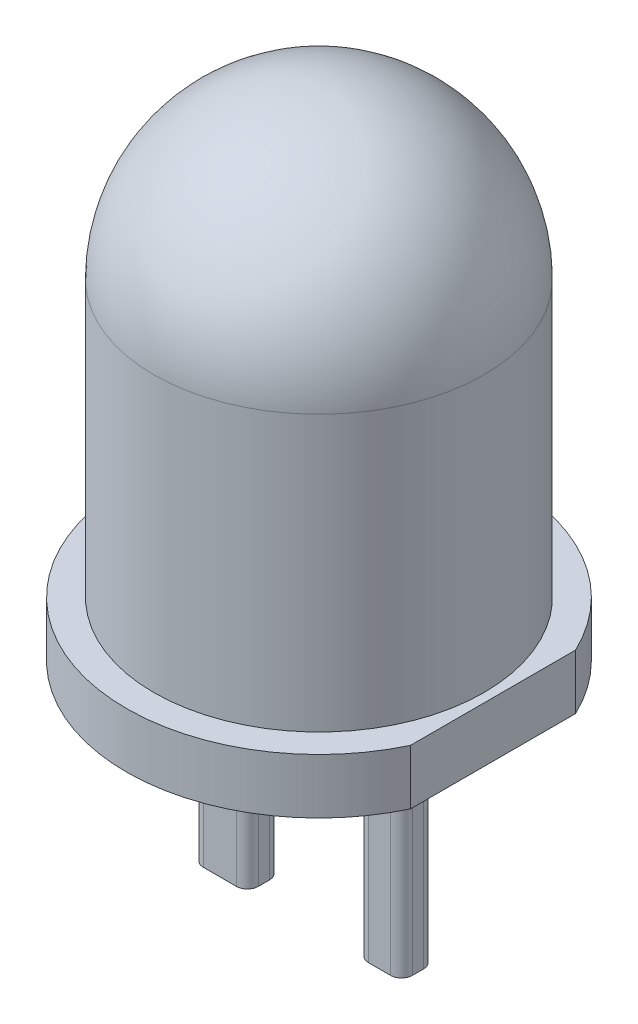
from build123d import *

# Parameters (mm, degrees)
SCHNITT_LINEAR_AUSTRAGEN1_DEPTH = 1
LINEAR_AUSTRAGEN1_DEPTH         = 2


with BuildPart() as part:
    # Skizze2 → Rotation1 (revolve)
    with BuildSketch(Plane.XY):
        with BuildLine():
            Line((0, 0), (-1.75, 0))
            Line((-1.75, 0), (-1.75, 0.5))
            Line((-1.75, 0.5), (-1.5, 0.5))
            Line((-1.5, 0.5), (-1.5, 3))
            ThreePointArc((-1.5, 3), (-1.060660172, 4.060660172), (0, 4.5))
            Line((0, 4.5), (0, 0))
        make_face()
    revolve(axis=Axis((0, 0, 0), (0, 1, 0)))

    # Skizze3 → Schnitt-Linear austragen1 (cut)
    with BuildSketch(Plane.XZ):
        with BuildLine():
            Line((1.58113883, -0.75), (1.58113883, 0.75))
            ThreePointArc((1.58113883, 0.75), (1.75, 0), (1.58113883, -0.75))
        make_face()
    extrude(amount=-SCHNITT_LINEAR_AUSTRAGEN1_DEPTH, mode=Mode.SUBTRACT)

    # Skizze4 → Linear austragen1 (add)
    with BuildSketch(Plane.XZ):
        with BuildLine():
            Line((0.6, 0.15), (0.8, 0.15))
            ThreePointArc((0.8, 0.15), (0.870710678, 0.120710678), (0.9, 0.05))
            Line((0.9, 0.05), (0.9, -0.05))
            ThreePointArc((0.9, -0.05), (0.870710678, -0.120710678), (0.8, -0.15))
            Line((0.8, -0.15), (0.6, -0.15))
            ThreePointArc((0.6, -0.15), (0.529289322, -0.120710678), (0.5, -0.05))
            Line((0.5, -0.05), (0.5, 0.05))
            ThreePointArc((0.5, 0.05), (0.529289322, 0.120710678), (0.6, 0.15))
        make_face()
        with BuildLine():
            Line((-0.9, 0.15), (-0.6, 0.15))
            ThreePointArc((-0.6, 0.15), (-0.529289322, 0.120710678), (-0.5, 0.05))
            Line((-0.5, 0.05), (-0.5, -0.05))
            ThreePointArc((-0.5, -0.05), (-0.529289322, -0.120710678), (-0.6, -0.15))
            Line((-0.6, -0.15), (-0.9, -0.15))
            ThreePointArc((-0.9, -0.15), (-0.970710678, -0.120710678), (-1, -0.05))
            Line((-1, -0.05), (-1, 0.05))
            ThreePointArc((-1, 0.05), (-0.970710678, 0.120710678), (-0.9, 0.15))
        make_face()
    extrude(amount=LINEAR_AUSTRAGEN1_DEPTH)


solid = part.part
